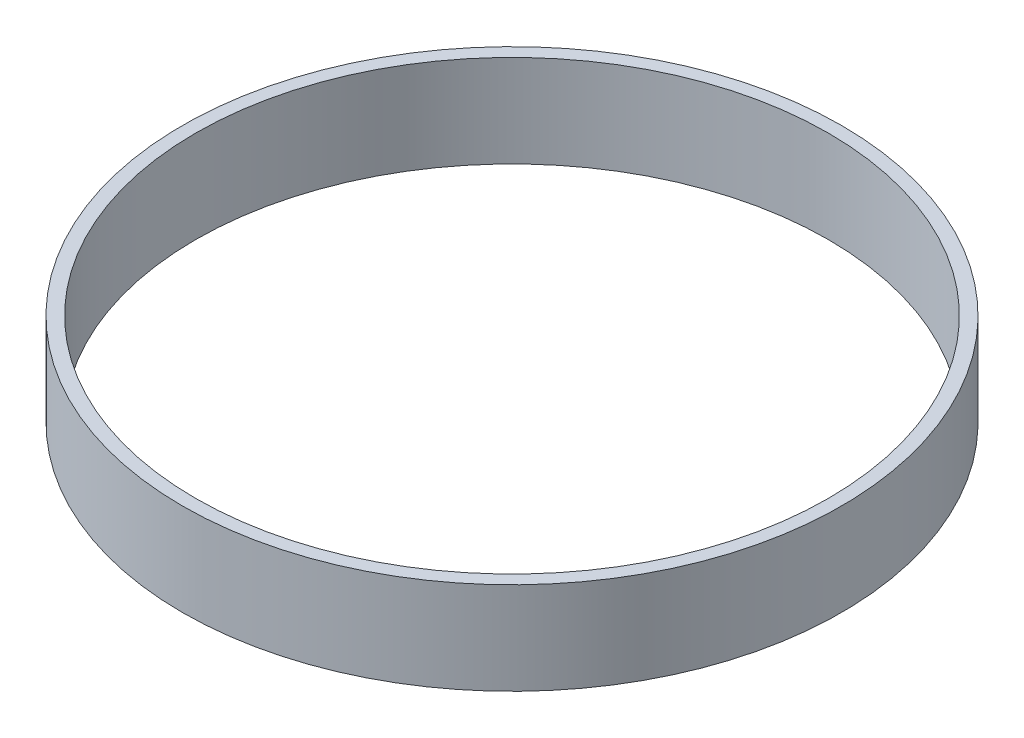
from build123d import *

# Parameters (mm, degrees)
SKETCH1_R           = 75
SKETCH1_R_2         = 72
BOSS_EXTRUDE1_DEPTH = 21


with BuildPart() as part:
    # Sketch1 → Boss-Extrude1 (new body)
    with BuildSketch(Plane(origin=(0, 0, 0), x_dir=(1, 0, 0), z_dir=(0, 1, 0))):
        Circle(SKETCH1_R)
        Circle(SKETCH1_R_2, mode=Mode.SUBTRACT)
    extrude(amount=BOSS_EXTRUDE1_DEPTH)


solid = part.part
